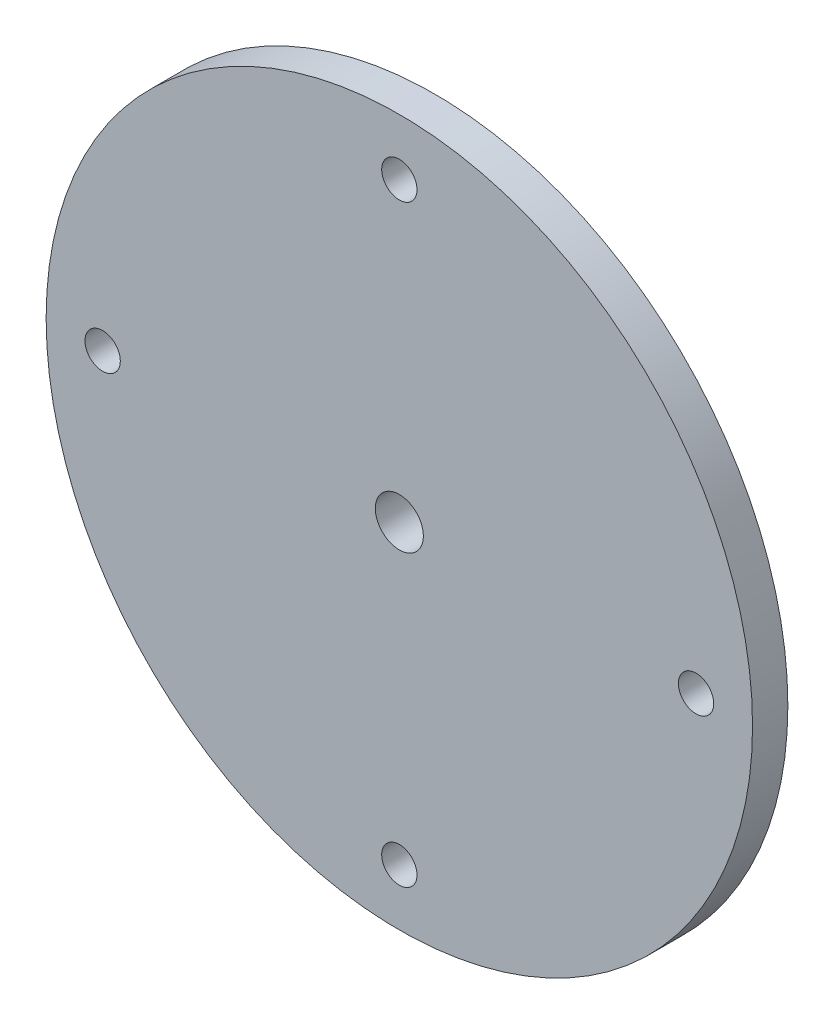
from build123d import *

# Parameters (mm, degrees)
SKETCH1_R              = 14
SKETCH1_R_2            = 12.5
BOSS_EXTRUDE1_DEPTH    = 2
SKETCH2_R              = 14
SKETCH2_W              = 17.67766953
SKETCH2_H              = 17.67766953
BOSS_EXTRUDE2_DEPTH    = 5
SKETCH3_R              = 14
BOSS_EXTRUDE3_DEPTH    = 5
SKETCH6_R              = 50
BOSS_EXTRUDE4_DEPTH    = 5
M8X1_25_TAPPED_HOLE1_D = 6.8
M6X1_0_TAPPED_HOLE1_D  = 5
FILLET1_R              = 6


with BuildPart() as part:
    # Sketch1 → Boss-Extrude1 (new body)
    with BuildSketch(Plane.XY):
        Circle(SKETCH1_R)
        Circle(SKETCH1_R_2, mode=Mode.SUBTRACT)
    extrude(amount=BOSS_EXTRUDE1_DEPTH)

    # Sketch2 → Boss-Extrude2 (add)
    with BuildSketch(Plane.XY.offset(2)):
        Circle(SKETCH2_R)
        Rectangle(SKETCH2_W, SKETCH2_H, mode=Mode.SUBTRACT)
    extrude(amount=BOSS_EXTRUDE2_DEPTH)

    # Sketch3 → Boss-Extrude3 (add)
    with BuildSketch(Plane.XY.offset(7)):
        Circle(SKETCH3_R)
    extrude(amount=BOSS_EXTRUDE3_DEPTH)

    # Sketch6 → Boss-Extrude4 (add)
    with BuildSketch(Plane.XY.offset(12)):
        Circle(SKETCH6_R)
    extrude(amount=-BOSS_EXTRUDE4_DEPTH)

    # M8x1.25 Tapped Hole1 (through all)
    with Locations(Plane.XY.offset(12)):
        with Locations((0, 0)):
            Hole(M8X1_25_TAPPED_HOLE1_D / 2)

    # M6x1.0 Tapped Hole1 (through all)
    with Locations(Plane.XY.offset(12)):
        with Locations((0, 42), (42, 0), (0, -42), (-42, 0)):
            Hole(M6X1_0_TAPPED_HOLE1_D / 2)

    # Fillet1
    fillet1_edges = [part.edges().sort_by_distance(p)[0] for p in [
        (-14, 0, 7),
    ]]
    fillet(fillet1_edges, radius=FILLET1_R)


solid = part.part
